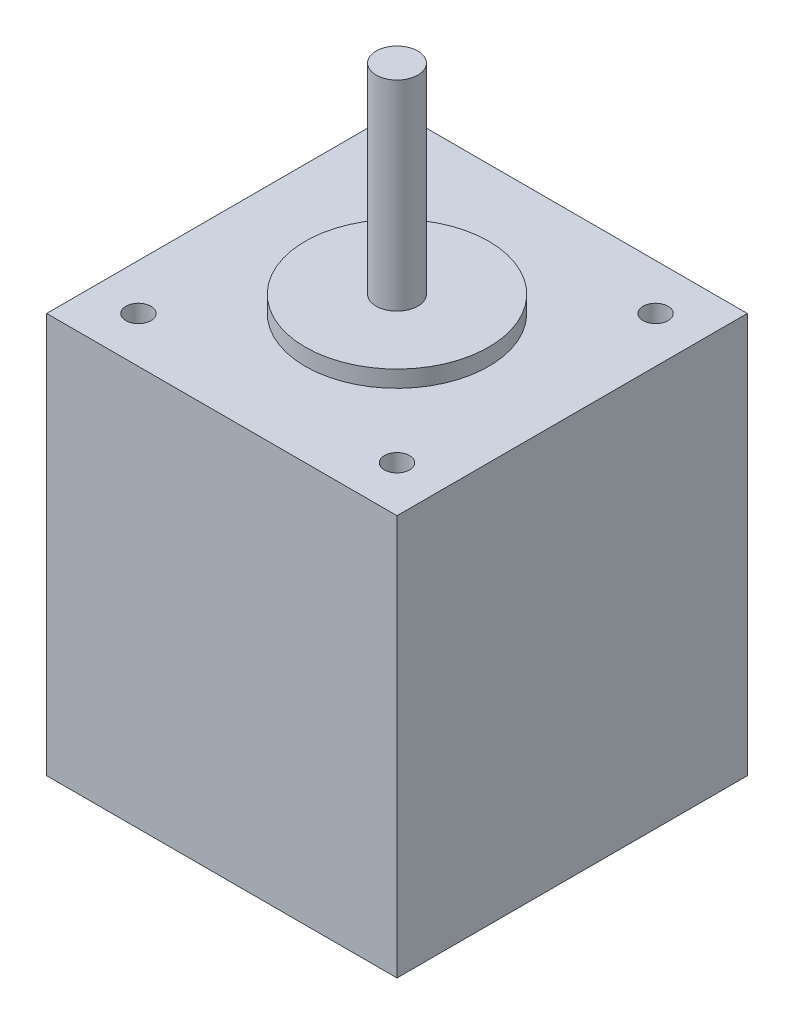
from build123d import *

# Parameters (mm, degrees)
SKETCH1_W           = 42
SKETCH1_H           = 42
BOSS_EXTRUDE1_DEPTH = 48
SKETCH5_R           = 11
BOSS_EXTRUDE4_DEPTH = 2
SKETCH6_R           = 2.5
BOSS_EXTRUDE5_DEPTH = 24
SKETCH8_R           = 1.5
CUT_EXTRUDE1_DEPTH  = 4.5


with BuildPart() as part:
    # Sketch1 → Boss-Extrude1 (new body)
    with BuildSketch(Plane(origin=(0, 0, 0), x_dir=(1, 0, 0), z_dir=(0, 1, 0))):
        with Locations((21, 21)):
            Rectangle(SKETCH1_W, SKETCH1_H)
    extrude(amount=BOSS_EXTRUDE1_DEPTH)

    # Sketch5 → Boss-Extrude4 (add)
    with BuildSketch(Plane(origin=(0, 48, 0), x_dir=(1, 0, 0), z_dir=(0, 1, 0))):
        with Locations((21, 21)):
            Circle(SKETCH5_R)
    extrude(amount=BOSS_EXTRUDE4_DEPTH)

    # Sketch6 → Boss-Extrude5 (add)
    with BuildSketch(Plane(origin=(0, 50, 0), x_dir=(1, 0, 0), z_dir=(0, 1, 0))):
        with Locations((21, 21)):
            Circle(SKETCH6_R)
    extrude(amount=BOSS_EXTRUDE5_DEPTH)

    # Sketch8 → Cut-Extrude1 (cut)
    with BuildSketch(Plane(origin=(0, 48, 0), x_dir=(1, 0, 0), z_dir=(0, 1, 0))):
        with Locations((36.5, 5.5)):
            Circle(SKETCH8_R)
        with Locations((36.5, 36.5)):
            Circle(SKETCH8_R)
        with Locations((5.5, 5.5)):
            Circle(SKETCH8_R)
        with Locations((5.5, 36.5)):
            Circle(SKETCH8_R)
    extrude(amount=-CUT_EXTRUDE1_DEPTH, mode=Mode.SUBTRACT)


solid = part.part
